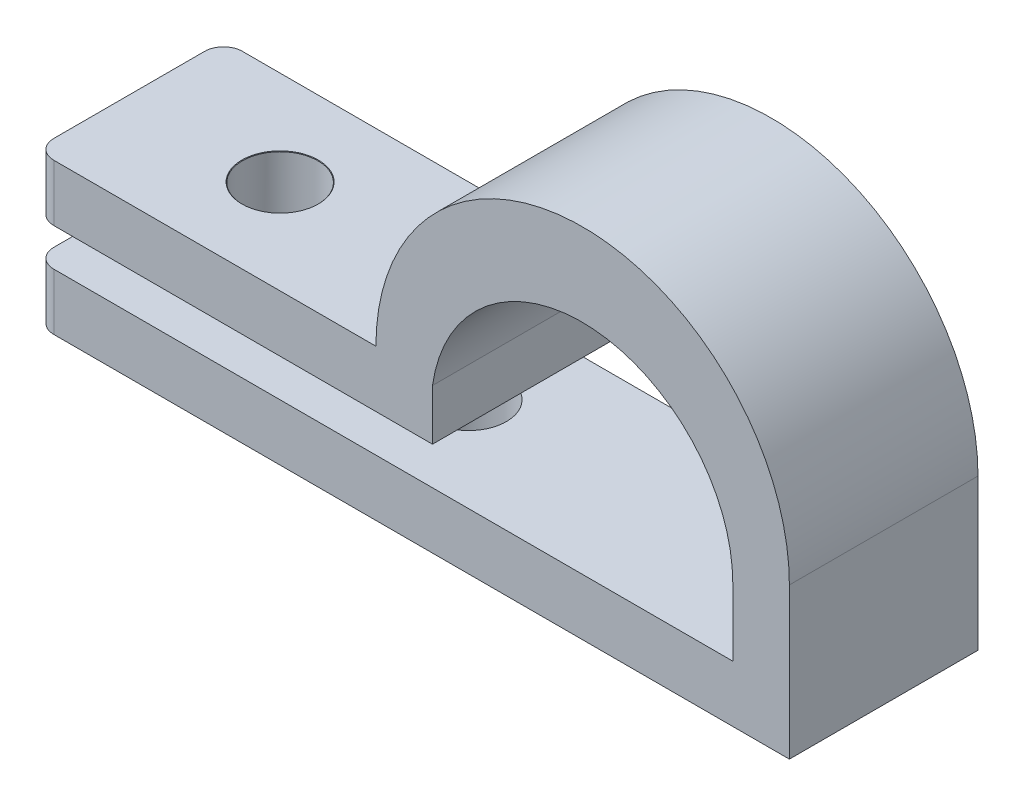
from build123d import *

# Parameters (mm, degrees)
BOSS_EXTRUDE1_DEPTH            = 5
BOSS_EXTRUDE1_DEPTH_BACK       = 5
FILLET1_R                      = 1
F_4_0MM_DOWEL_HOLE1_AT_2_COUNT = 2
F_4_0MM_DOWEL_HOLE1_AT_2_PITCH = 10


with BuildPart() as part:
    # Sketch1 → Boss-Extrude1 (new, two sides: drawn at the far end of the back side and taken through both)
    with BuildSketch(Plane.XY.offset(-BOSS_EXTRUDE1_DEPTH_BACK)):
        with BuildLine():
            Line((0, 0), (40, 0))
            Line((40, 0), (40, 8))
            ThreePointArc((40, 8), (29.039542787, 18.960457213), (18.079085573, 8))
            Line((18.079085573, 8), (0, 8))
            Line((0, 8), (0, 5))
            Line((0, 5), (21.079085573, 5))
            Line((21.079085573, 5), (21.079085573, 7.695472827))
            ThreePointArc((21.079085573, 7.695472827), (29.562443146, 14.553574165), (37, 6.57337005))
            Line((37, 6.57337005), (37, 3))
            Line((37, 3), (0, 3))
            Line((0, 3), (0, 0))
        make_face()
    extrude(amount=BOSS_EXTRUDE1_DEPTH + BOSS_EXTRUDE1_DEPTH_BACK)

    # Fillet1
    fillet1_edges = [part.edges().sort_by_distance(p)[0] for p in [
        (0, 1.5, 5),
        (0, 6.5, 5),
        (0, 1.5, -5),
        (0, 6.5, -5),
    ]]
    fillet(fillet1_edges, radius=FILLET1_R)

    # Sketch5 → Ø4.0mm Dowel Hole1 (revolve, cut)
    with BuildSketch(Plane(origin=(8, 8, 0), x_dir=(0, 0, 1), z_dir=(1, 0, 0))):
        Polygon((0, 0), (0, 8), (2, 8), (2, 0.025), (2.025, 0), align=None)
    f_4_0mm_dowel_hole1 = revolve(axis=Axis((8, 14.35, 0), (0, -1, 0)), mode=Mode.SUBTRACT)

    # Ø4.0mm Dowel Hole1 at 2: Ø4.0mm Dowel Hole1 ×2
    with Locations(*[(i * F_4_0MM_DOWEL_HOLE1_AT_2_PITCH, 0, 0) for i in range(1, F_4_0MM_DOWEL_HOLE1_AT_2_COUNT)]):
        add(f_4_0mm_dowel_hole1, mode=Mode.SUBTRACT)


solid = part.part
